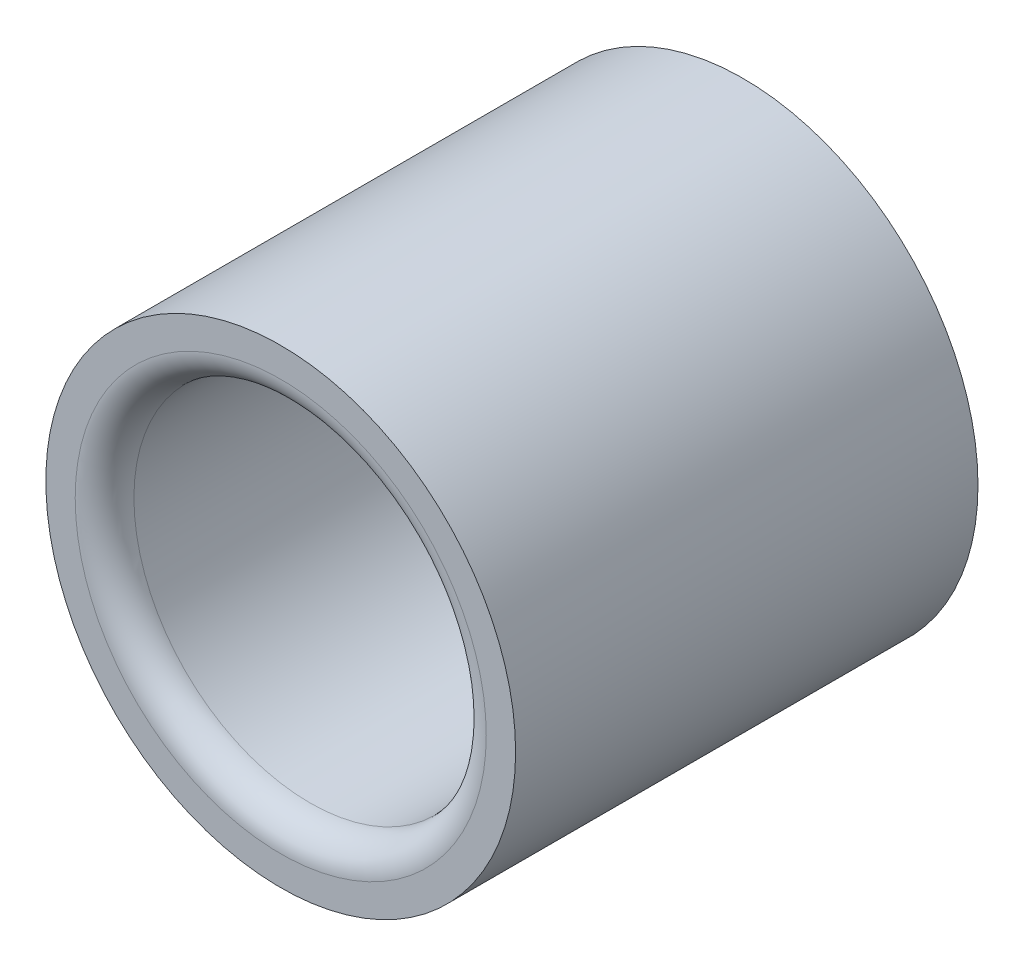
from build123d import *

# Parameters (mm, degrees)
SKETCH1_R           = 1.27
SKETCH1_R_2         = 0.9525
BOSS_EXTRUDE1_DEPTH = 2.5
FILLET3_R           = 0.15875


with BuildPart() as part:
    # Sketch1 → Boss-Extrude1 (new body)
    with BuildSketch(Plane.XY):
        Circle(SKETCH1_R)
        Circle(SKETCH1_R_2, mode=Mode.SUBTRACT)
    extrude(amount=BOSS_EXTRUDE1_DEPTH)

    # Fillet3
    fillet3_edges = [part.edges().sort_by_distance(p)[0] for p in [
        (-0.9525, 0, 2.5),
        (-0.9525, 0, 0),
    ]]
    fillet(fillet3_edges, radius=FILLET3_R)


solid = part.part
